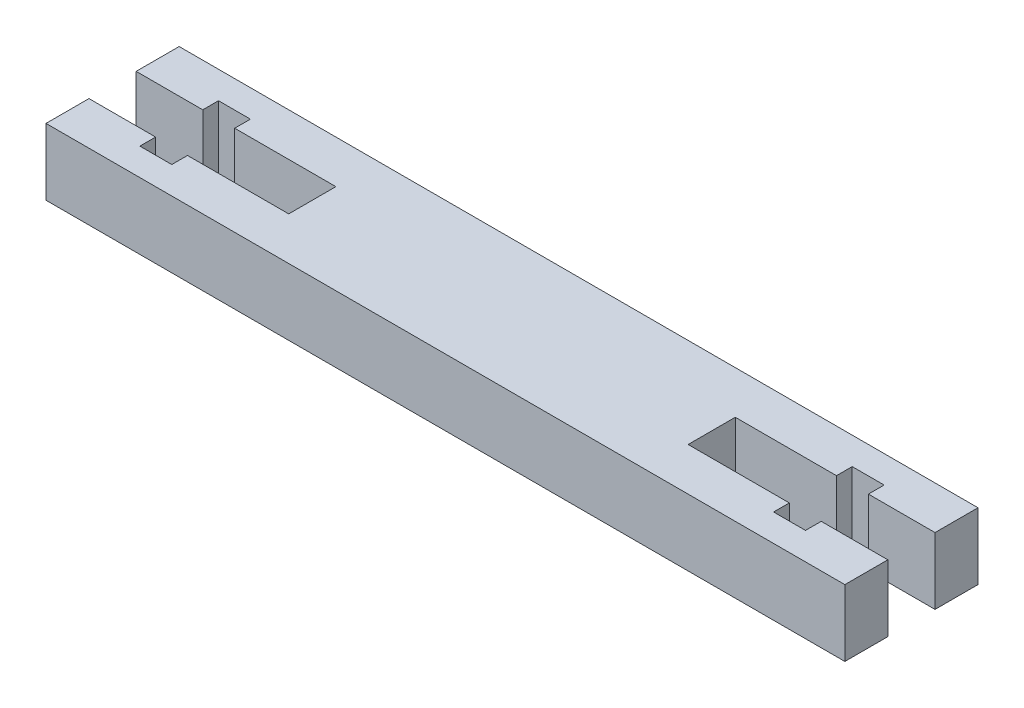
from build123d import *

# Parameters (mm, degrees)
SKETCH1_W               = 76.2
SKETCH1_H               = 12.7
BOSS_EXTRUDE1_DEPTH     = 6.35
CUT_EXTRUDE1_DEPTH      = 1
CUT_EXTRUDE1_DEPTH_BACK = 7.35


with BuildPart() as part:
    # Sketch1 → Boss-Extrude1 (new body)
    with BuildSketch(Plane(origin=(0, 0, 0), x_dir=(1, 0, 0), z_dir=(0, 1, 0))):
        with Locations((38.1, -6.35)):
            Rectangle(SKETCH1_W, SKETCH1_H)
    extrude(amount=BOSS_EXTRUDE1_DEPTH)

    # Sketch2 → Cut-Extrude1 (cut, two sides)
    with BuildSketch(Plane(origin=(0, 0, 0), x_dir=(-1, 0, 0), z_dir=(0, -1, 0))) as cut_extrude1_sk:
        Polygon((-76.2, -8.6), (-76.2, -4.1), (-69.845872794, -4.1), (-69.845872794, -2.6), (-66.802, -2.6), (-66.802, -4.1), (-57.149530135, -4.1), (-57.149530135, -8.6), (-66.802, -8.6), (-66.802, -10.1), (-69.845872794, -10.1), (-69.845872794, -8.6), align=None)
        Polygon((-19.050469865, -4.1), (-9.398, -4.1), (-9.398, -2.6), (-6.354127206, -2.6), (-6.354127206, -4.1), (0, -4.1), (0, -8.6), (-6.354127206, -8.6), (-6.354127206, -10.1), (-9.398, -10.1), (-9.398, -8.6), (-19.050469865, -8.6), align=None)
    extrude(amount=CUT_EXTRUDE1_DEPTH, mode=Mode.SUBTRACT)
    extrude(cut_extrude1_sk.sketch, amount=-CUT_EXTRUDE1_DEPTH_BACK, mode=Mode.SUBTRACT)


solid = part.part
